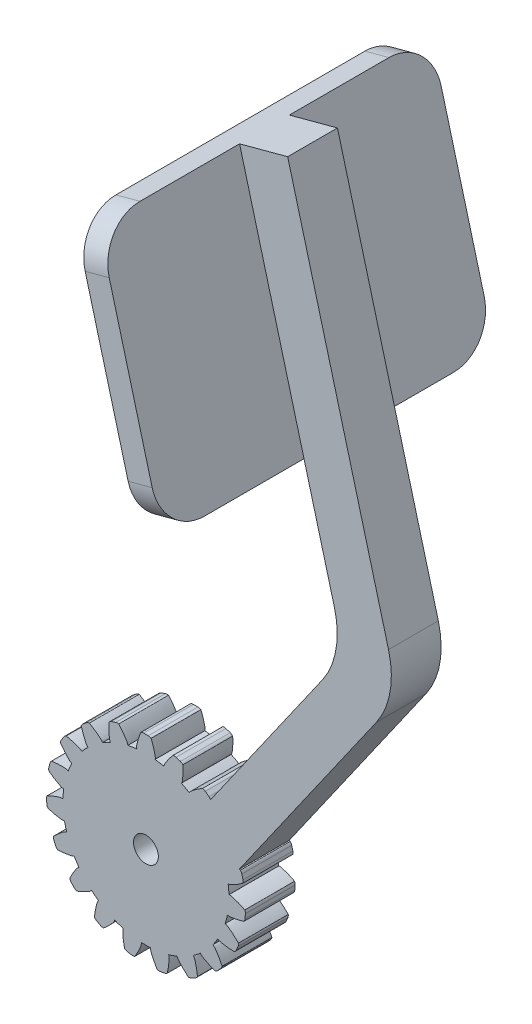
from build123d import *

# Parameters (mm, degrees)
SKETCH1_R           = 1.5
BOSS_EXTRUDE1_DEPTH = 6
CIRPATTERN1_COUNT   = 19
BOSS_EXTRUDE2_DEPTH = 6
BOSS_EXTRUDE3_DEPTH = 3


with BuildPart() as part:
    # Sketch1 → Boss-Extrude1 (new body)
    with BuildSketch(Plane.XY):
        with BuildLine():
            Line((0.275, 11.999315872), (-0.275, 11.999315872))
            ThreePointArc((-0.275, 11.999315872), (-0.454505322, 11.973992778), (-0.62, 11.9))
            add(Edge.make_bspline(
                [(-1.1, 9.939315872), (-1.275278826, 10.183872011), (-0.664438698, 11.87210283), (-0.62, 11.9)],
                knots=[0, 0, 0, 0, 1, 1, 1, 1], degree=3))
            ThreePointArc((-1.1, 9.939315872), (0, -10), (1.1, 9.939315872))
            add(Edge.make_bspline(
                [(1.1, 9.939315872), (1.275278826, 10.183872011), (0.664438698, 11.87210283), (0.62, 11.9)],
                knots=[0, 0, 0, 0, 1, 1, 1, 1], degree=3))
            ThreePointArc((0.62, 11.9), (0.454505322, 11.973992778), (0.275, 11.999315872))
        make_face()
        Circle(SKETCH1_R, mode=Mode.SUBTRACT)
    boss_extrude1 = extrude(amount=BOSS_EXTRUDE1_DEPTH)

    # CirPattern1: Boss-Extrude1 ×19 about axis
    cirpattern1_axis = Axis((0, 0, 6), (0, 0, -1))
    for i in range(1, CIRPATTERN1_COUNT):
        add(boss_extrude1.rotate(cirpattern1_axis, i * 360 / CIRPATTERN1_COUNT))

    # Sketch2 → Boss-Extrude2 (add)
    with BuildSketch(Plane.XY):
        with BuildLine():
            Line((8.757969549, 0), (3.843057283, 3.441458618))
            Line((3.843057283, 3.441458618), (21.243601708, 28.292011454))
            ThreePointArc((21.243601708, 28.292011454), (22.900158795, 32.291294041), (22.711339528, 36.615966268))
            Line((22.711339528, 36.615966268), (11.281890496, 79.271250757))
            Line((11.281890496, 79.271250757), (17.077445454, 80.824165028))
            Line((17.077445454, 80.824165028), (29.231030302, 35.466368879))
            ThreePointArc((29.231030302, 35.466368879), (29.419849569, 31.141696651), (27.763292482, 27.142414064))
            Line((27.763292482, 27.142414064), (8.757969549, 0))
        make_face()
    extrude(amount=BOSS_EXTRUDE2_DEPTH)

    # Sketch3 → Boss-Extrude3 (add)
    with BuildSketch(Plane(origin=(30.343959823, 8.13063953, 0), x_dir=(0, 0, 1), z_dir=(-0.965925826, -0.258819045, 0))):
        with BuildLine():
            Line((-12, 43.650180264), (18, 43.650180264))
            ThreePointArc((18, 43.650180264), (21.535533906, 45.114646358), (23, 48.650180264))
            Line((23, 48.650180264), (23, 68.650180264))
            ThreePointArc((23, 68.650180264), (21.535533906, 72.18571417), (18, 73.650180264))
            Line((18, 73.650180264), (-12, 73.650180264))
            ThreePointArc((-12, 73.650180264), (-15.535533906, 72.18571417), (-17, 68.650180264))
            Line((-17, 68.650180264), (-17, 48.650180264))
            ThreePointArc((-17, 48.650180264), (-15.535533906, 45.114646358), (-12, 43.650180264))
        make_face()
    extrude(amount=BOSS_EXTRUDE3_DEPTH)


solid = part.part
